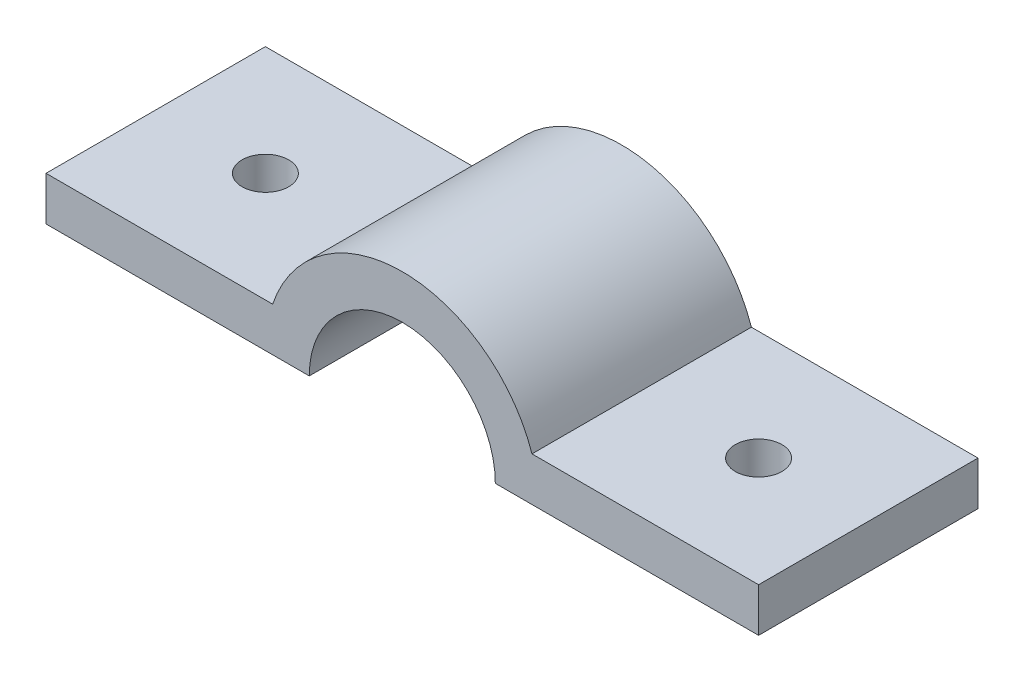
from build123d import *

# Parameters (mm, degrees)
BOSS_EXTRUDE1_DEPTH = 31.75
SKETCH3_R           = 3.3782
CUT_EXTRUDE1_DEPTH  = 7.35


with BuildPart() as part:
    # Sketch1 → Boss-Extrude1 (new body)
    with BuildSketch(Plane.XY):
        with BuildLine():
            Line((32.795198354, 6.35), (0, 6.35))
            Line((0, 6.35), (0, 0))
            Line((0, 0), (38.1, 0))
            ThreePointArc((38.1, 0), (51.562, 13.462), (65.024, 0))
            Line((65.024, 0), (103.124, 0))
            Line((103.124, 0), (103.124, 6.35))
            Line((103.124, 6.35), (70.328801646, 6.35))
            ThreePointArc((70.328801646, 6.35), (51.562, 19.812), (32.795198354, 6.35))
        make_face()
    extrude(amount=BOSS_EXTRUDE1_DEPTH)

    # Sketch3 → Cut-Extrude1 (cut, through all)
    with BuildSketch(Plane(origin=(0, 6.35, 0), x_dir=(1, 0, 0), z_dir=(0, 1, 0))):
        with Locations((15.875, -15.875)):
            Circle(SKETCH3_R)
        with Locations((87.249, -15.875)):
            Circle(SKETCH3_R)
    extrude(amount=-CUT_EXTRUDE1_DEPTH, mode=Mode.SUBTRACT)


solid = part.part
